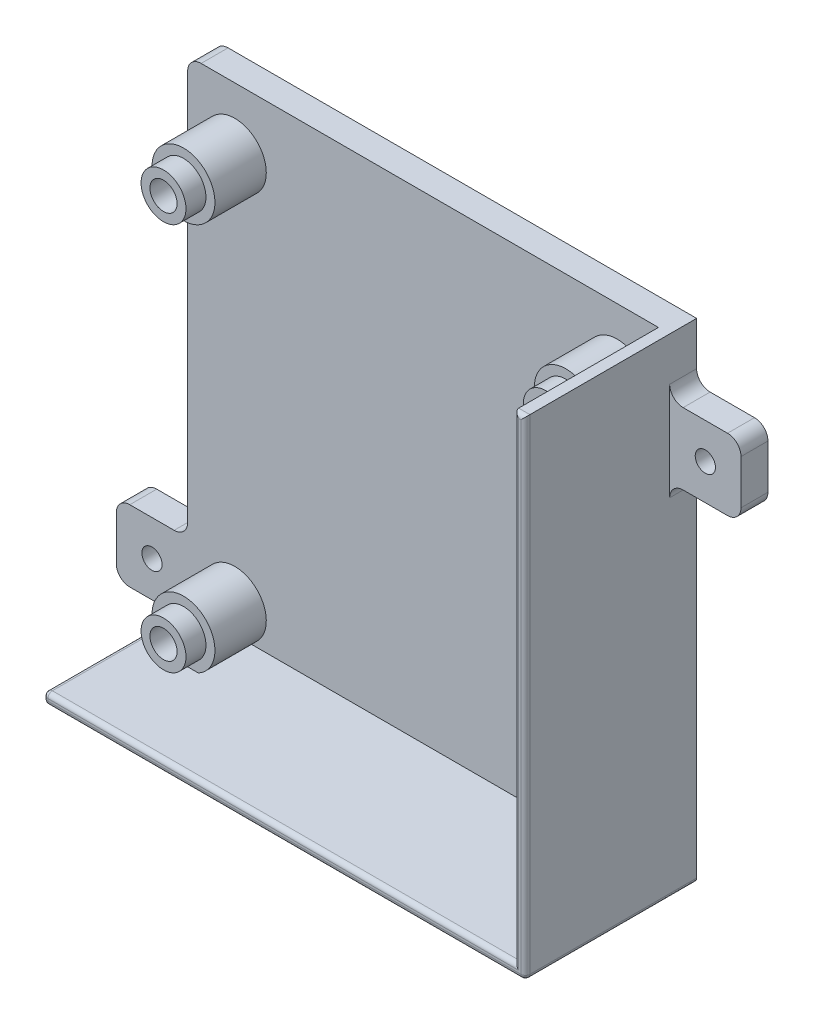
from build123d import *

# Parameters (mm, degrees)
SKETCH1_W            = 104.775
SKETCH1_H            = 106.3625
BOSS_EXTRUDE1_DEPTH  = 6
BOSS_EXTRUDE2_DEPTH  = 38.1
SKETCH3_R            = 5
SKETCH3_R_2          = 3.025
BOSS_EXTRUDE3_DEPTH  = 15.875
SKETCH4_R            = 7
SKETCH4_R_2          = 3.025
BOSS_EXTRUDE4_DEPTH  = 11.43
BOSS_EXTRUDE5_DEPTH  = 6
M4_CLEARANCE_HOLE1_D = 4.5
FILLET2_R            = 3
FILLET3_R            = 1


with BuildPart() as part:
    # Sketch1 → Boss-Extrude1 (new body)
    with BuildSketch(Plane.XY):
        Rectangle(SKETCH1_W, SKETCH1_H)
    extrude(amount=BOSS_EXTRUDE1_DEPTH)

    # Sketch2 → Boss-Extrude2 (add)
    with BuildSketch(Plane.XY):
        Polygon((-52.3875, -53.18125), (-52.3875, -55.68125), (54.8875, -55.68125), (54.8875, 53.18125), (52.3875, 53.18125), (52.3875, -53.18125), align=None)
    extrude(amount=BOSS_EXTRUDE2_DEPTH)

    # Sketch3 → Boss-Extrude3 (add)
    with BuildSketch(Plane.XY.offset(6)):
        with Locations((43.208, 39.35095)):
            Circle(SKETCH3_R)
        with Locations((43.208, 39.35095)):
            Circle(SKETCH3_R_2, mode=Mode.SUBTRACT)
        with Locations((-41.882, 39.35095)):
            Circle(SKETCH3_R)
        with Locations((-41.882, 39.35095)):
            Circle(SKETCH3_R_2, mode=Mode.SUBTRACT)
        with Locations((-41.882, -47.00905)):
            Circle(SKETCH3_R)
        with Locations((-41.882, -47.00905)):
            Circle(SKETCH3_R_2, mode=Mode.SUBTRACT)
        with Locations((43.208, -47.00905)):
            Circle(SKETCH3_R)
        with Locations((43.208, -47.00905)):
            Circle(SKETCH3_R_2, mode=Mode.SUBTRACT)
    extrude(amount=BOSS_EXTRUDE3_DEPTH)

    # Sketch4 → Boss-Extrude4 (add)
    with BuildSketch(Plane.XY.offset(6)):
        with Locations((43.208, 39.35095)):
            Circle(SKETCH4_R)
        with Locations((43.208, 39.35095)):
            Circle(SKETCH4_R_2, mode=Mode.SUBTRACT)
        with Locations((-41.882, 39.35095)):
            Circle(SKETCH4_R)
        with Locations((-41.882, 39.35095)):
            Circle(SKETCH4_R_2, mode=Mode.SUBTRACT)
        with Locations((-41.882, -47.00905)):
            Circle(SKETCH4_R)
        with Locations((-41.882, -47.00905)):
            Circle(SKETCH4_R_2, mode=Mode.SUBTRACT)
        with Locations((43.208, -47.00905)):
            Circle(SKETCH4_R)
        with Locations((43.208, -47.00905)):
            Circle(SKETCH4_R_2, mode=Mode.SUBTRACT)
    extrude(amount=BOSS_EXTRUDE4_DEPTH)

    # Sketch6 → Boss-Extrude5 (add)
    with BuildSketch(Plane.XY):
        Polygon((-52.3875, -55.68125), (-52.3875, -39.80625), (-68.2625, -39.80625), align=None)
        Polygon((-68.2625, -55.68125), (-68.2625, -39.80625), (-52.3875, -55.68125), align=None)
        Polygon((54.8875, 24.60625), (70.7625, 40.48125), (70.7625, 24.60625), align=None)
        Polygon((54.8875, 40.48125), (54.8875, 24.60625), (70.7625, 40.48125), align=None)
    extrude(amount=BOSS_EXTRUDE5_DEPTH)

    # M4 Clearance Hole1 (through all)
    with Locations(Plane.XY.offset(6)):
        with Locations((62.825, 32.54375), (-60.325, -47.74375)):
            Hole(M4_CLEARANCE_HOLE1_D / 2)

    # Fillet2
    fillet2_edges = [part.edges().sort_by_distance(p)[0] for p in [
        (-52.3875, -39.80625, 3),
        (-68.2625, -39.80625, 3),
        (-68.2625, -55.68125, 3),
        (70.7625, 24.60625, 3),
        (70.7625, 40.48125, 3),
        (54.8875, 40.48125, 3),
        (54.8875, 24.60625, 3),
        (-52.3875, 53.18125, 3),
    ]]
    fillet(fillet2_edges, radius=FILLET2_R)

    # Fillet3
    fillet3_edges = [part.edges().sort_by_distance(p)[0] for p in [
        (-52.3875, -53.18125, 22.05),
        (-52.3875, -55.68125, 22.05),
        (54.8875, -55.68125, 19.05),
        (0, -53.18125, 38.1),
        (-52.3875, -54.43125, 38.1),
        (1.25, -55.68125, 38.1),
        (54.8875, -1.25, 38.1),
        (53.6375, 53.18125, 38.1),
        (52.3875, 0, 38.1),
    ]]
    fillet(fillet3_edges, radius=FILLET3_R)


solid = part.part
